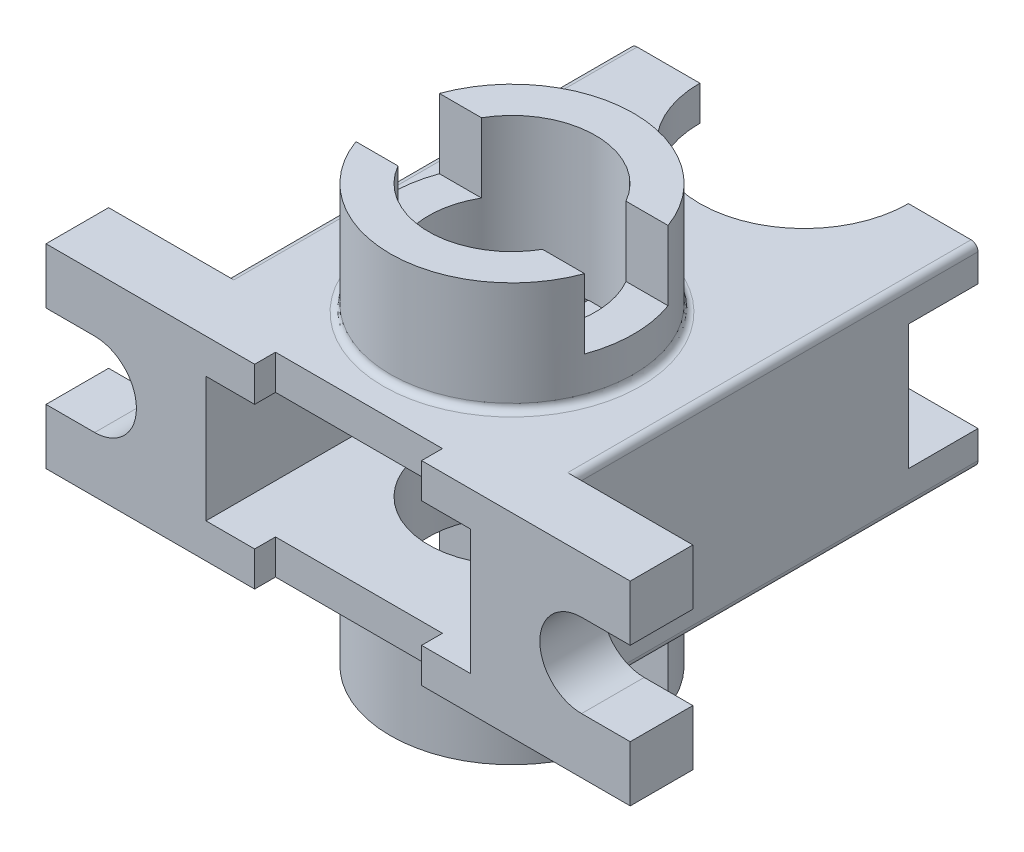
from build123d import *

# Parameters (mm, degrees)
SKETCH1_R               = 17.5
SKETCH1_R_2             = 12
BOSS_EXTRUDE1_DEPTH     = 30
BOSS_EXTRUDE2_DEPTH     = 14
CUT_EXTRUDE1_DEPTH      = 10
SKETCH8_W               = 84
SKETCH8_H               = 18
CUT_EXTRUDE2_DEPTH      = 19
SKETCH9_W               = 10
SKETCH9_H               = 18
CUT_EXTRUDE3_DEPTH      = 68
SKETCH10_W              = 12
SKETCH10_H              = 10
CUT_EXTRUDE4_DEPTH      = 43
CUT_EXTRUDE4_DEPTH_BACK = 43
CUT_EXTRUDE5_REACH      = 69
SKETCH7_R               = 4
FILLET2_R               = 1


with BuildPart() as part:
    # Sketch1 → Boss-Extrude1 (new body, symmetric)
    with BuildSketch(Plane(origin=(0, 0, 0), x_dir=(1, 0, 0), z_dir=(0, 1, 0))):
        Circle(SKETCH1_R)
        Circle(SKETCH1_R_2, mode=Mode.SUBTRACT)
    extrude(amount=BOSS_EXTRUDE1_DEPTH, both=True)

    # Sketch5 → Boss-Extrude2 (add, symmetric)
    with BuildSketch(Plane(origin=(0, 0, 0), x_dir=(1, 0, 0), z_dir=(0, 1, 0))):
        Polygon((42, -16), (-42, -16), (-42, -25), (-12, -25), (-12, -22), (12, -22), (12, -25), (42, -25), align=None)
        with BuildLine():
            Line((-25, 42), (-25, -16))
            Line((-25, -16), (-7.088723439, -16))
            ThreePointArc((-7.088723439, -16), (0, 17.5), (7.088723439, -16))
            Line((7.088723439, -16), (25, -16))
            Line((25, -16), (25, 42))
            Line((25, 42), (15, 42))
            ThreePointArc((15, 42), (0, 27), (-15, 42))
            Line((-15, 42), (-25, 42))
        make_face()
    extrude(amount=BOSS_EXTRUDE2_DEPTH, both=True)

    # Sketch6 → Cut-Extrude1 (cut, through all)
    with BuildSketch(Plane(origin=(0, 0, 16), x_dir=(-1, 0, 0), z_dir=(0, 0, -1))):
        with BuildLine():
            Line((35, 6), (49, 6))
            ThreePointArc((49, 6), (55, 0), (49, -6))
            Line((49, -6), (35, -6))
            ThreePointArc((35, -6), (29, 0), (35, 6))
        make_face()
        with BuildLine():
            Line((-35, 6), (-49, 6))
            ThreePointArc((-49, 6), (-55, 0), (-49, -6))
            Line((-49, -6), (-35, -6))
            ThreePointArc((-35, -6), (-29, 0), (-35, 6))
        make_face()
    extrude(amount=-CUT_EXTRUDE1_DEPTH, mode=Mode.SUBTRACT)

    # Sketch8 → Cut-Extrude2 (cut, symmetric)
    with BuildSketch(Plane(origin=(0, 0, 0), x_dir=(0, 0, -1), z_dir=(1, 0, 0))):
        Rectangle(SKETCH8_W, SKETCH8_H)
    extrude(amount=CUT_EXTRUDE2_DEPTH, both=True, mode=Mode.SUBTRACT)

    # Sketch9 → Cut-Extrude3 (cut, through all)
    with BuildSketch(Plane.ZY.offset(25)):
        with Locations((-37, 0)):
            Rectangle(SKETCH9_W, SKETCH9_H)
    extrude(amount=-CUT_EXTRUDE3_DEPTH, mode=Mode.SUBTRACT)

    # Sketch10 → Cut-Extrude4 (cut, two sides)
    with BuildSketch(Plane(origin=(0, 0, 0), x_dir=(0, 0, -1), z_dir=(1, 0, 0))) as cut_extrude4_sk:
        with Locations((0, -25)):
            Rectangle(SKETCH10_W, SKETCH10_H)
        with Locations((0, 25)):
            Rectangle(SKETCH10_W, SKETCH10_H)
    extrude(amount=CUT_EXTRUDE4_DEPTH, mode=Mode.SUBTRACT)
    extrude(cut_extrude4_sk.sketch, amount=-CUT_EXTRUDE4_DEPTH_BACK, mode=Mode.SUBTRACT)

    # Sketch7 → Cut-Extrude5 (cut, up to next)
    with BuildSketch(Plane.ZY.offset(25), mode=Mode.PRIVATE) as cut_extrude5_sk1:
        with Locations((-12, 0)):
            Circle(SKETCH7_R)
    cut_extrude5_tool1 = extrude(cut_extrude5_sk1.sketch, amount=-CUT_EXTRUDE5_REACH, mode=Mode.PRIVATE) & part.part
    add(cut_extrude5_tool1.solids().sort_by_distance((-25, 0, -12))[0], mode=Mode.SUBTRACT)

    # Fillet2
    fillet2_edges = [part.edges().sort_by_distance(p)[0] for p in [
        (-17.5, -14, 0),
        (-17.5, 14, 0),
        (25, 14, -13),
        (-25, 14, -13),
        (-25, -14, -13),
        (25, -14, -13),
    ]]
    fillet(fillet2_edges, radius=FILLET2_R)


solid = part.part
